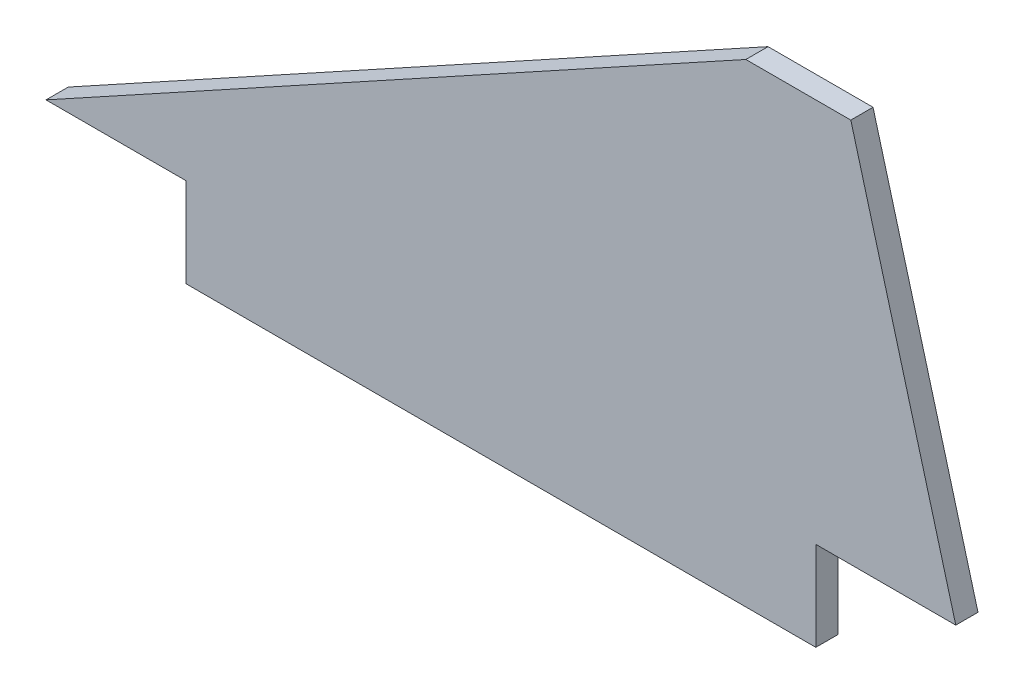
from build123d import *

# Parameters (mm, degrees)
BOSS_EXTRUDE1_DEPTH = 3.175


with BuildPart() as part:
    # Sketch1 → Boss-Extrude1 (new body)
    with BuildSketch(Plane.XY):
        Polygon((0, 0), (20, 0), (20, -12.75), (110, -12.75), (110, 0), (130, 0), (115, 55), (100, 55), align=None)
    extrude(amount=BOSS_EXTRUDE1_DEPTH)


solid = part.part
